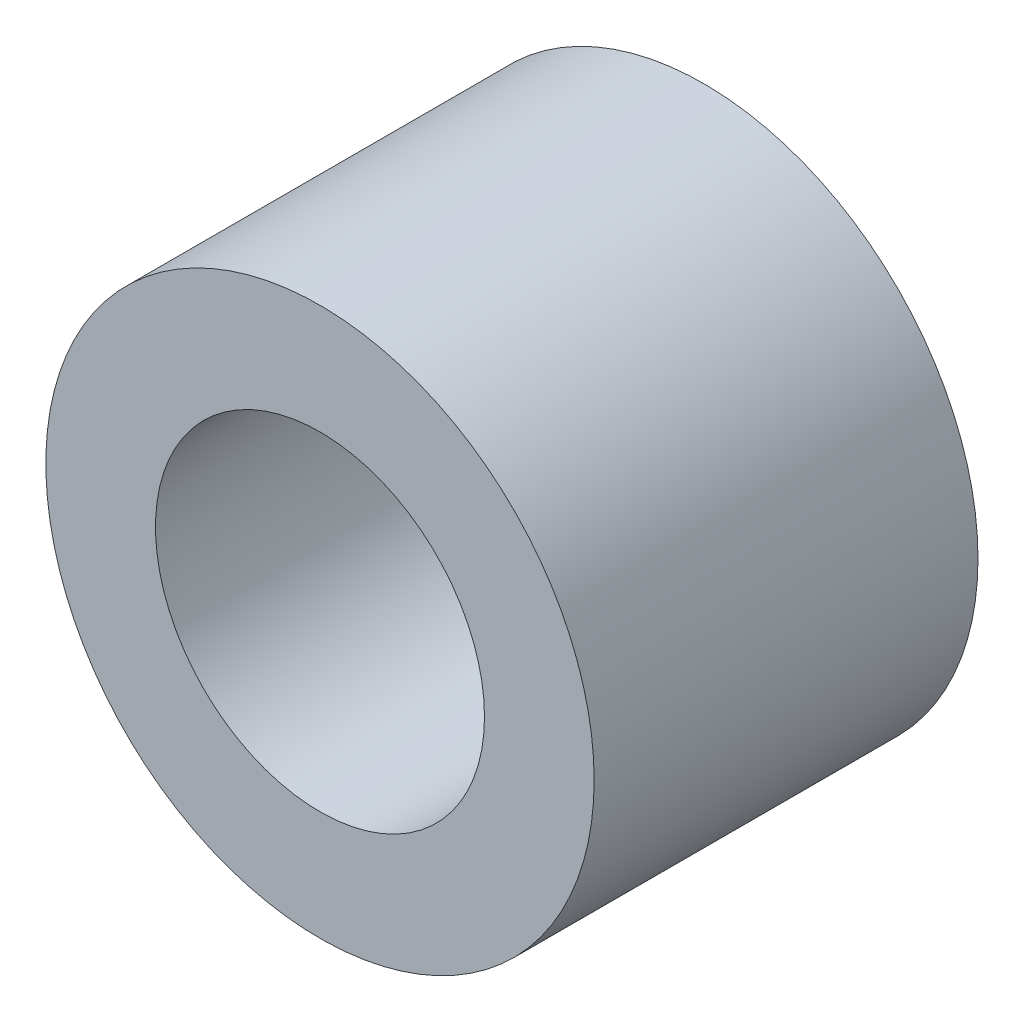
from build123d import *

# Parameters (mm, degrees)
SKETCH2_R           = 2.5
SKETCH2_R_2         = 1.5
BOSS_EXTRUDE1_DEPTH = 3.5


with BuildPart() as part:
    # Sketch2 → Boss-Extrude1 (new body)
    with BuildSketch(Plane.XY):
        Circle(SKETCH2_R)
        Circle(SKETCH2_R_2, mode=Mode.SUBTRACT)
    extrude(amount=BOSS_EXTRUDE1_DEPTH)


solid = part.part
